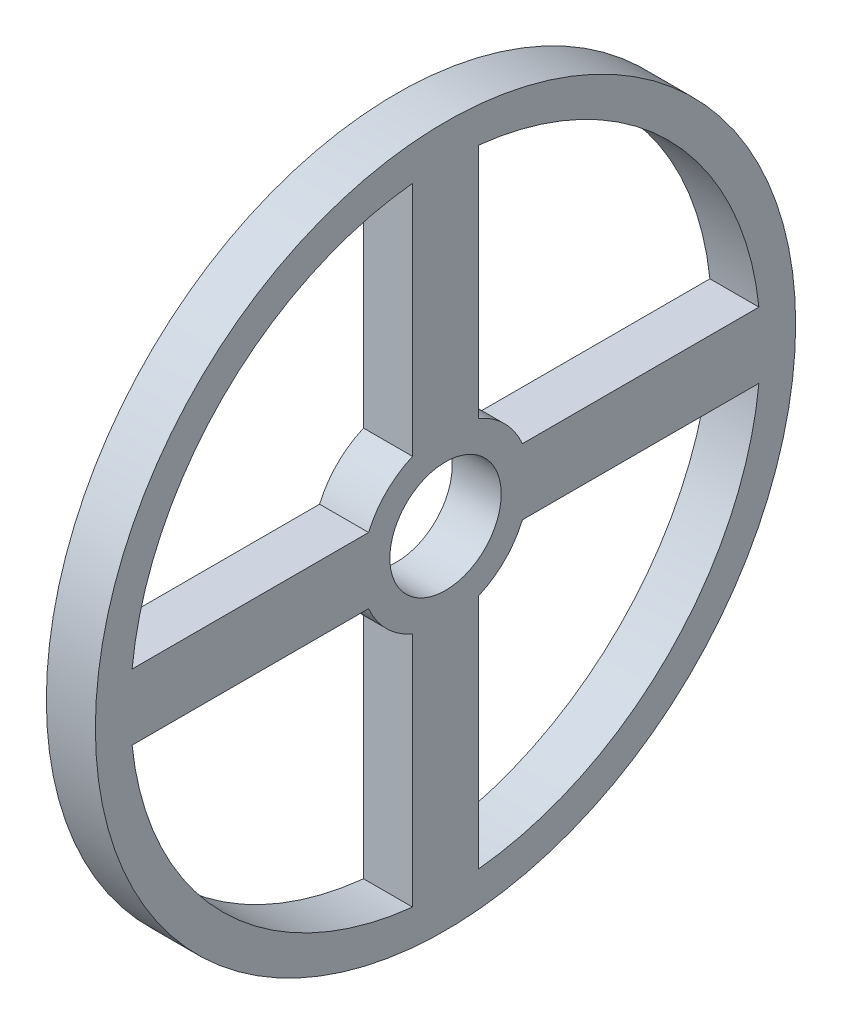
from build123d import *

# Parameters (mm, degrees)
SKETCH3_R           = 50
BOSS_EXTRUDE3_DEPTH = 7


with BuildPart() as part:
    # Sketch3 → Boss-Extrude3 (new body)
    with BuildSketch(Plane(origin=(0, 0, 0), x_dir=(0, 0, -1), z_dir=(1, 0, 0))):
        Circle(SKETCH3_R)
        with BuildLine():
            Line((-4.708862012, -10.983128814), (-4.708862012, -44.752950948))
            ThreePointArc((-4.708862012, -44.752950948), (-31.819805153, -31.819805153), (-44.752950948, -4.708862012))
            Line((-44.752950948, -4.708862012), (-10.983128814, -4.708862012))
            ThreePointArc((-10.983128814, -4.708862012), (-8.449926035, -8.449926035), (-4.708862012, -10.983128814))
        make_face(mode=Mode.SUBTRACT)
        with BuildLine():
            Line((10.983128814, -4.708862012), (44.752950948, -4.708862012))
            ThreePointArc((44.752950948, -4.708862012), (31.819805153, -31.819805153), (4.708862012, -44.752950948))
            Line((4.708862012, -44.752950948), (4.708862012, -10.983128814))
            ThreePointArc((4.708862012, -10.983128814), (8.449926035, -8.449926035), (10.983128814, -4.708862012))
        make_face(mode=Mode.SUBTRACT)
        with BuildLine():
            ThreePointArc((-44.752950948, 4.708862012), (-31.819805153, 31.819805153), (-4.708862012, 44.752950948))
            Line((-4.708862012, 44.752950948), (-4.708862012, 10.983128814))
            ThreePointArc((-4.708862012, 10.983128814), (-8.449926035, 8.449926035), (-10.983128814, 4.708862012))
            Line((-10.983128814, 4.708862012), (-44.752950948, 4.708862012))
        make_face(mode=Mode.SUBTRACT)
        with BuildLine():
            ThreePointArc((-1.652897942, 7.776273426), (-0.831001283, 7.906449068), (0, 7.95))
            ThreePointArc((0, 7.95), (0.831001283, 7.906449068), (1.652897942, 7.776273426))
            ThreePointArc((1.652897942, 7.776273426), (2.456685105, 7.560899305), (3.233556312, 7.262686388))
            ThreePointArc((3.233556312, 7.262686388), (3.975, 6.88490196), (4.672892756, 6.431685105))
            ThreePointArc((4.672892756, 6.431685105), (5.319588321, 5.908001363), (5.908001363, 5.319588321))
            ThreePointArc((5.908001363, 5.319588321), (6.431685105, 4.672892756), (6.88490196, 3.975))
            ThreePointArc((6.88490196, 3.975), (7.262686388, 3.233556312), (7.560899305, 2.456685105))
            ThreePointArc((7.560899305, 2.456685105), (7.776273426, 1.652897942), (7.906449068, 0.831001283))
            ThreePointArc((7.906449068, 0.831001283), (7.939104801, 0.416070852), (7.95, 0))
            ThreePointArc((7.95, 0), (7.939104801, -0.416070852), (7.906449068, -0.831001283))
            ThreePointArc((7.906449068, -0.831001283), (7.776273426, -1.652897942), (7.560899305, -2.456685105))
            ThreePointArc((7.560899305, -2.456685105), (7.262686388, -3.233556312), (6.88490196, -3.975))
            ThreePointArc((6.88490196, -3.975), (6.431685105, -4.672892756), (5.908001363, -5.319588321))
            ThreePointArc((5.908001363, -5.319588321), (5.319588321, -5.908001363), (4.672892756, -6.431685105))
            ThreePointArc((4.672892756, -6.431685105), (3.975, -6.88490196), (3.233556312, -7.262686388))
            ThreePointArc((3.233556312, -7.262686388), (2.456685105, -7.560899305), (1.652897942, -7.776273426))
            ThreePointArc((1.652897942, -7.776273426), (0.831001283, -7.906449068), (0, -7.95))
            ThreePointArc((0, -7.95), (-0.831001283, -7.906449068), (-1.652897942, -7.776273426))
            ThreePointArc((-1.652897942, -7.776273426), (-2.456685105, -7.560899305), (-3.233556312, -7.262686388))
            ThreePointArc((-3.233556312, -7.262686388), (-3.975, -6.88490196), (-4.672892756, -6.431685105))
            ThreePointArc((-4.672892756, -6.431685105), (-5.319588321, -5.908001363), (-5.908001363, -5.319588321))
            ThreePointArc((-5.908001363, -5.319588321), (-6.431685105, -4.672892756), (-6.88490196, -3.975))
            ThreePointArc((-6.88490196, -3.975), (-7.262686388, -3.233556312), (-7.560899305, -2.456685105))
            ThreePointArc((-7.560899305, -2.456685105), (-7.776273426, -1.652897942), (-7.906449068, -0.831001283))
            ThreePointArc((-7.906449068, -0.831001283), (-7.95, 0), (-7.906449068, 0.831001283))
            ThreePointArc((-7.906449068, 0.831001283), (-7.776273426, 1.652897942), (-7.560899305, 2.456685105))
            ThreePointArc((-7.560899305, 2.456685105), (-7.262686388, 3.233556312), (-6.88490196, 3.975))
            ThreePointArc((-6.88490196, 3.975), (-6.431685105, 4.672892756), (-5.908001363, 5.319588321))
            ThreePointArc((-5.908001363, 5.319588321), (-5.319588321, 5.908001363), (-4.672892756, 6.431685105))
            ThreePointArc((-4.672892756, 6.431685105), (-3.975, 6.88490196), (-3.233556312, 7.262686388))
            ThreePointArc((-3.233556312, 7.262686388), (-2.456685105, 7.560899305), (-1.652897942, 7.776273426))
        make_face(mode=Mode.SUBTRACT)
        with BuildLine():
            Line((4.708862012, 10.983128814), (4.708862012, 44.752950948))
            ThreePointArc((4.708862012, 44.752950948), (31.819805153, 31.819805153), (44.752950948, 4.708862012))
            Line((44.752950948, 4.708862012), (10.983128814, 4.708862012))
            ThreePointArc((10.983128814, 4.708862012), (8.449926035, 8.449926035), (4.708862012, 10.983128814))
        make_face(mode=Mode.SUBTRACT)
    extrude(amount=BOSS_EXTRUDE3_DEPTH)


solid = part.part
